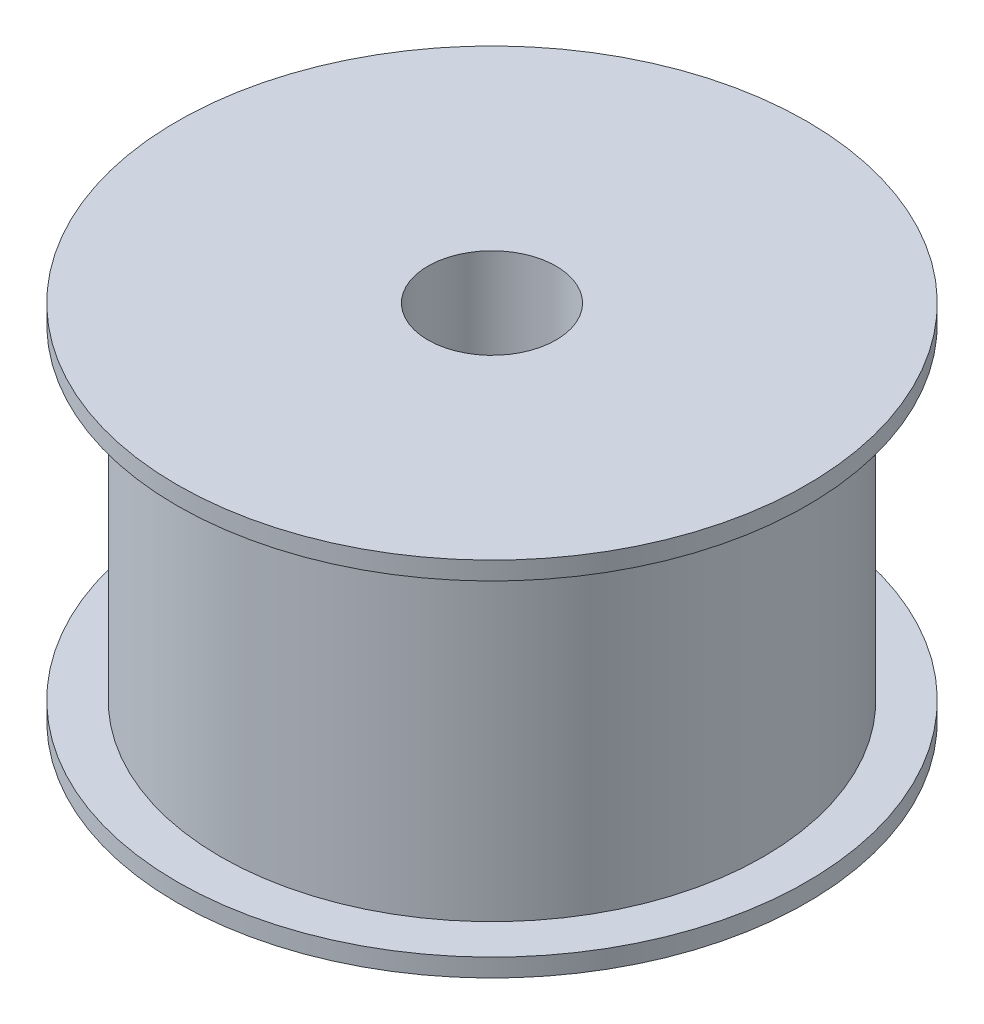
from build123d import *

# Parameters (mm, degrees)
F_8_CLEARANCE_HOLE1_D = 4.4958


with BuildPart() as part:
    # Sketch1 → Revolve1 (revolve)
    with BuildSketch(Plane.XY):
        Polygon((11.049, 0), (0, 0), (0, 12.7), (11.049, 12.7), (11.049, 12.065), (9.525, 12.065), (9.525, 0.635), (11.049, 0.635), align=None)
    revolve(axis=Axis((0, 0, 0), (0, 1, 0)))

    # #8 Clearance Hole1 (through all)
    with Locations(Plane(origin=(0, 12.7, 0), x_dir=(1, 0, 0), z_dir=(0, 1, 0))):
        with Locations((0, 0)):
            Hole(F_8_CLEARANCE_HOLE1_D / 2)


solid = part.part
